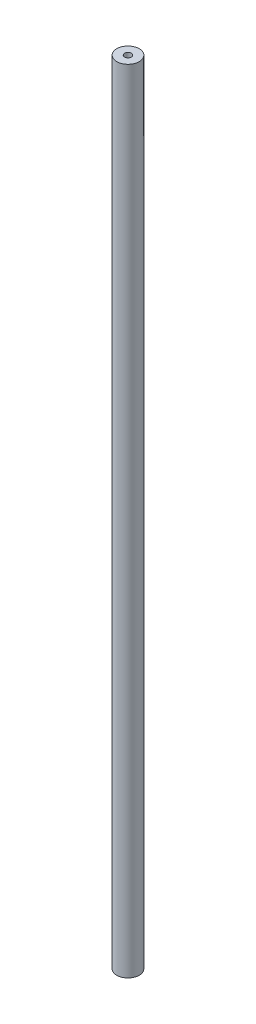
from build123d import *

# Parameters (mm, degrees)
SKETCH1_R           = 5
BOSS_EXTRUDE1_DEPTH = 353
SKETCH2_R           = 1.5
CUT_EXTRUDE1_DEPTH  = 10


with BuildPart() as part:
    # Sketch1 → Boss-Extrude1 (new body)
    with BuildSketch(Plane(origin=(0, 0, 0), x_dir=(1, 0, 0), z_dir=(0, 1, 0))):
        Circle(SKETCH1_R)
    extrude(amount=BOSS_EXTRUDE1_DEPTH)

    # Sketch2 → Cut-Extrude1 (cut)
    with BuildSketch(Plane(origin=(0, 353, 0), x_dir=(1, 0, 0), z_dir=(0, 1, 0))):
        Circle(SKETCH2_R)
    extrude(amount=-CUT_EXTRUDE1_DEPTH, mode=Mode.SUBTRACT)


solid = part.part
